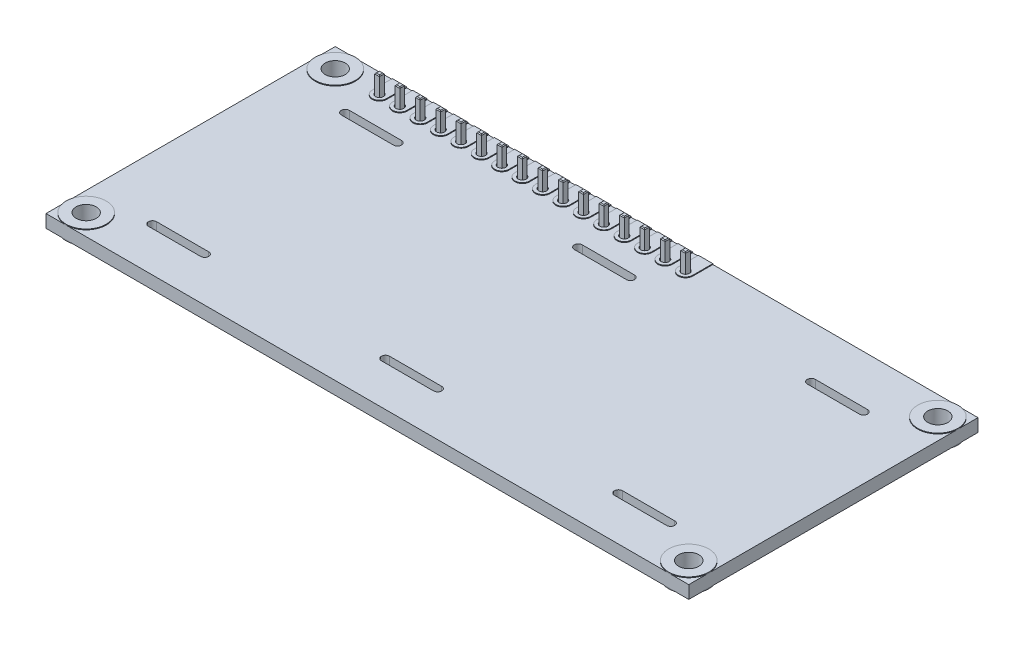
from build123d import *

# Parameters (mm, degrees)
SKETCH1_W           = 80
SKETCH1_H           = 36
SKETCH1_R           = 1.25
SKETCH1_R_2         = 0.5
BOSS_EXTRUDE1_DEPTH = 1.6
SKETCH2_R           = 0.5
BOSS_EXTRUDE2_DEPTH = 0.1
LPATTERN1_COUNT     = 16
LPATTERN1_PITCH     = 2.54
SKETCH3_R           = 2.5
SKETCH3_R_2         = 1.25
BOSS_EXTRUDE3_DEPTH = 0.1
SKETCH4_R           = 2.5
SKETCH4_R_2         = 1.25
BOSS_EXTRUDE4_DEPTH = 0.1
BOSS_EXTRUDE5_START = -9.9
SKETCH5_W           = 0.6
SKETCH5_H           = 0.6
BOSS_EXTRUDE5_DEPTH = 12.1
SKETCH6_W           = 0.6
SKETCH6_H           = 0.6
BOSS_EXTRUDE6_DEPTH = 0.1
BOSS_EXTRUDE6_TAPER = 45
SKETCH7_W           = 0.6
SKETCH7_H           = 0.6
BOSS_EXTRUDE7_DEPTH = 0.1
BOSS_EXTRUDE7_TAPER = 45
LPATTERN2_COUNT     = 16
LPATTERN2_PITCH     = 2.54
SKETCH8_W           = 40.5
SKETCH8_H           = 2.5
BOSS_EXTRUDE8_DEPTH = 2.5


with BuildPart() as part:
    # Sketch1 → Boss-Extrude1 (new body)
    with BuildSketch(Plane(origin=(0, 0, 0), x_dir=(1, 0, 0), z_dir=(0, 1, 0))):
        Rectangle(SKETCH1_W, SKETCH1_H)
        with Locations((-37.5, 15.5)):
            Circle(SKETCH1_R, mode=Mode.SUBTRACT)
        with Locations((-37.5, -15.5)):
            Circle(SKETCH1_R, mode=Mode.SUBTRACT)
        with Locations((37.5, 15.5)):
            Circle(SKETCH1_R, mode=Mode.SUBTRACT)
        with Locations((37.5, -15.5)):
            Circle(SKETCH1_R, mode=Mode.SUBTRACT)
        with Locations((-32, 15.5)):
            Circle(SKETCH1_R_2, mode=Mode.SUBTRACT)
        with Locations((-29.46, 15.5)):
            Circle(SKETCH1_R_2, mode=Mode.SUBTRACT)
        with Locations((-26.92, 15.5)):
            Circle(SKETCH1_R_2, mode=Mode.SUBTRACT)
        with Locations((-24.38, 15.5)):
            Circle(SKETCH1_R_2, mode=Mode.SUBTRACT)
        with Locations((-21.84, 15.5)):
            Circle(SKETCH1_R_2, mode=Mode.SUBTRACT)
        with Locations((-19.3, 15.5)):
            Circle(SKETCH1_R_2, mode=Mode.SUBTRACT)
        with Locations((-16.76, 15.5)):
            Circle(SKETCH1_R_2, mode=Mode.SUBTRACT)
        with Locations((-14.22, 15.5)):
            Circle(SKETCH1_R_2, mode=Mode.SUBTRACT)
        with Locations((-11.68, 15.5)):
            Circle(SKETCH1_R_2, mode=Mode.SUBTRACT)
        with Locations((-9.14, 15.5)):
            Circle(SKETCH1_R_2, mode=Mode.SUBTRACT)
        with Locations((-6.6, 15.5)):
            Circle(SKETCH1_R_2, mode=Mode.SUBTRACT)
        with Locations((-4.06, 15.5)):
            Circle(SKETCH1_R_2, mode=Mode.SUBTRACT)
        with Locations((-1.52, 15.5)):
            Circle(SKETCH1_R_2, mode=Mode.SUBTRACT)
        with Locations((1.02, 15.5)):
            Circle(SKETCH1_R_2, mode=Mode.SUBTRACT)
        with Locations((3.56, 15.5)):
            Circle(SKETCH1_R_2, mode=Mode.SUBTRACT)
        with Locations((6.1, 15.5)):
            Circle(SKETCH1_R_2, mode=Mode.SUBTRACT)
        with BuildLine():
            Line((-3.25, -12), (3.25, -12))
            ThreePointArc((3.25, -12), (3.75, -12.5), (3.25, -13))
            Line((3.25, -13), (-3.25, -13))
            ThreePointArc((-3.25, -13), (-3.75, -12.5), (-3.25, -12))
        make_face(mode=Mode.SUBTRACT)
        with BuildLine():
            Line((25.75, -12), (32.25, -12))
            ThreePointArc((32.25, -12), (32.75, -12.5), (32.25, -13))
            Line((32.25, -13), (25.75, -13))
            ThreePointArc((25.75, -13), (25.25, -12.5), (25.75, -12))
        make_face(mode=Mode.SUBTRACT)
        with BuildLine():
            Line((25.75, 12), (32.25, 12))
            ThreePointArc((32.25, 12), (32.75, 11.5), (32.25, 11))
            Line((32.25, 11), (25.75, 11))
            ThreePointArc((25.75, 11), (25.25, 11.5), (25.75, 12))
        make_face(mode=Mode.SUBTRACT)
        with BuildLine():
            Line((-3.25, 12), (3.25, 12))
            ThreePointArc((3.25, 12), (3.75, 11.5), (3.25, 11))
            Line((3.25, 11), (-3.25, 11))
            ThreePointArc((-3.25, 11), (-3.75, 11.5), (-3.25, 12))
        make_face(mode=Mode.SUBTRACT)
        with BuildLine():
            Line((-32.25, -12), (-25.75, -12))
            ThreePointArc((-25.75, -12), (-25.25, -12.5), (-25.75, -13))
            Line((-25.75, -13), (-32.25, -13))
            ThreePointArc((-32.25, -13), (-32.75, -12.5), (-32.25, -12))
        make_face(mode=Mode.SUBTRACT)
        with BuildLine():
            Line((-32.25, 12), (-25.75, 12))
            ThreePointArc((-25.75, 12), (-25.25, 11.5), (-25.75, 11))
            Line((-25.75, 11), (-32.25, 11))
            ThreePointArc((-32.25, 11), (-32.75, 11.5), (-32.25, 12))
        make_face(mode=Mode.SUBTRACT)
    extrude(amount=-BOSS_EXTRUDE1_DEPTH)

    # Sketch2 → Boss-Extrude2 (add)
    with BuildSketch(Plane(origin=(0, 0, 0), x_dir=(1, 0, 0), z_dir=(0, 1, 0))):
        with BuildLine():
            Line((-32.9, 15.5), (-32.9, 18))
            Line((-32.9, 18), (-31.1, 18))
            Line((-31.1, 18), (-31.1, 15.5))
            ThreePointArc((-31.1, 15.5), (-32, 14.6), (-32.9, 15.5))
        make_face()
        with Locations((-32, 15.5)):
            Circle(SKETCH2_R, mode=Mode.SUBTRACT)
    boss_extrude2 = extrude(amount=BOSS_EXTRUDE2_DEPTH)

    # LPattern1: Boss-Extrude2 ×16
    with Locations(*[(i * LPATTERN1_PITCH, 0, 0) for i in range(1, LPATTERN1_COUNT)]):
        add(boss_extrude2)

    # Sketch3 → Boss-Extrude3 (add)
    with BuildSketch(Plane(origin=(0, 0, 0), x_dir=(1, 0, 0), z_dir=(0, 1, 0))):
        with Locations((-37.5, 15.5)):
            Circle(SKETCH3_R)
        with Locations((-37.5, 15.5)):
            Circle(SKETCH3_R_2, mode=Mode.SUBTRACT)
        with Locations((-37.5, -15.5)):
            Circle(SKETCH3_R)
        with Locations((-37.5, -15.5)):
            Circle(SKETCH3_R_2, mode=Mode.SUBTRACT)
        with Locations((37.5, -15.5)):
            Circle(SKETCH3_R)
        with Locations((37.5, -15.5)):
            Circle(SKETCH3_R_2, mode=Mode.SUBTRACT)
        with Locations((37.5, 15.5)):
            Circle(SKETCH3_R)
        with Locations((37.5, 15.5)):
            Circle(SKETCH3_R_2, mode=Mode.SUBTRACT)
    extrude(amount=BOSS_EXTRUDE3_DEPTH)

    # Sketch4 → Boss-Extrude4 (add)
    with BuildSketch(Plane.XZ.offset(1.6)):
        with Locations((37.5, -15.5)):
            Circle(SKETCH4_R)
        with Locations((37.5, -15.5)):
            Circle(SKETCH4_R_2, mode=Mode.SUBTRACT)
        with Locations((37.5, 15.5)):
            Circle(SKETCH4_R)
        with Locations((37.5, 15.5)):
            Circle(SKETCH4_R_2, mode=Mode.SUBTRACT)
        with Locations((-37.5, 15.5)):
            Circle(SKETCH4_R)
        with Locations((-37.5, 15.5)):
            Circle(SKETCH4_R_2, mode=Mode.SUBTRACT)
        with Locations((-37.5, -15.5)):
            Circle(SKETCH4_R)
        with Locations((-37.5, -15.5)):
            Circle(SKETCH4_R_2, mode=Mode.SUBTRACT)
    extrude(amount=BOSS_EXTRUDE4_DEPTH)



with BuildPart() as body_2:
    # Sketch5 → Boss-Extrude5 (new body)
    with BuildSketch(Plane(origin=(0, 0.1, 0), x_dir=(1, 0, 0), z_dir=(0, 1, 0)).offset(BOSS_EXTRUDE5_START)):
        with Locations((-32, 15.5)):
            Rectangle(SKETCH5_W, SKETCH5_H)
    boss_extrude5 = extrude(amount=BOSS_EXTRUDE5_DEPTH)

    # Sketch6 → Boss-Extrude6 (add)
    with BuildSketch(Plane(origin=(0, 2.3, 0), x_dir=(1, 0, 0), z_dir=(0, 1, 0))):
        with Locations((-32, 15.5)):
            Rectangle(SKETCH6_W, SKETCH6_H)
    boss_extrude6 = extrude(amount=BOSS_EXTRUDE6_DEPTH, taper=BOSS_EXTRUDE6_TAPER)

    # Sketch7 → Boss-Extrude7 (add)
    with BuildSketch(Plane.XZ.offset(9.8)):
        with Locations((-32, -15.5)):
            Rectangle(SKETCH7_W, SKETCH7_H)
    boss_extrude7 = extrude(amount=BOSS_EXTRUDE7_DEPTH, taper=BOSS_EXTRUDE7_TAPER)


with BuildPart() as lpattern2_1:
    # LPattern2: Boss-Extrude5, Boss-Extrude6, Boss-Extrude7 ×16
    with Locations(*[(i * LPATTERN2_PITCH, 0, 0) for i in range(1, LPATTERN2_COUNT)]):
        add(boss_extrude5)
        add(boss_extrude6)
        add(boss_extrude7)


with BuildPart() as part_1:
    add(part.part)

    add(body_2.part)  # Boss-Extrude8 merges body 2

    add(lpattern2_1.part)  # Boss-Extrude8 merges LPattern2_1
    # Sketch8 → Boss-Extrude8 (add)
    with BuildSketch(Plane.XZ.offset(1.6)):
        with Locations((-13, -15.5)):
            Rectangle(SKETCH8_W, SKETCH8_H)
    extrude(amount=BOSS_EXTRUDE8_DEPTH)


solid = part_1.part
